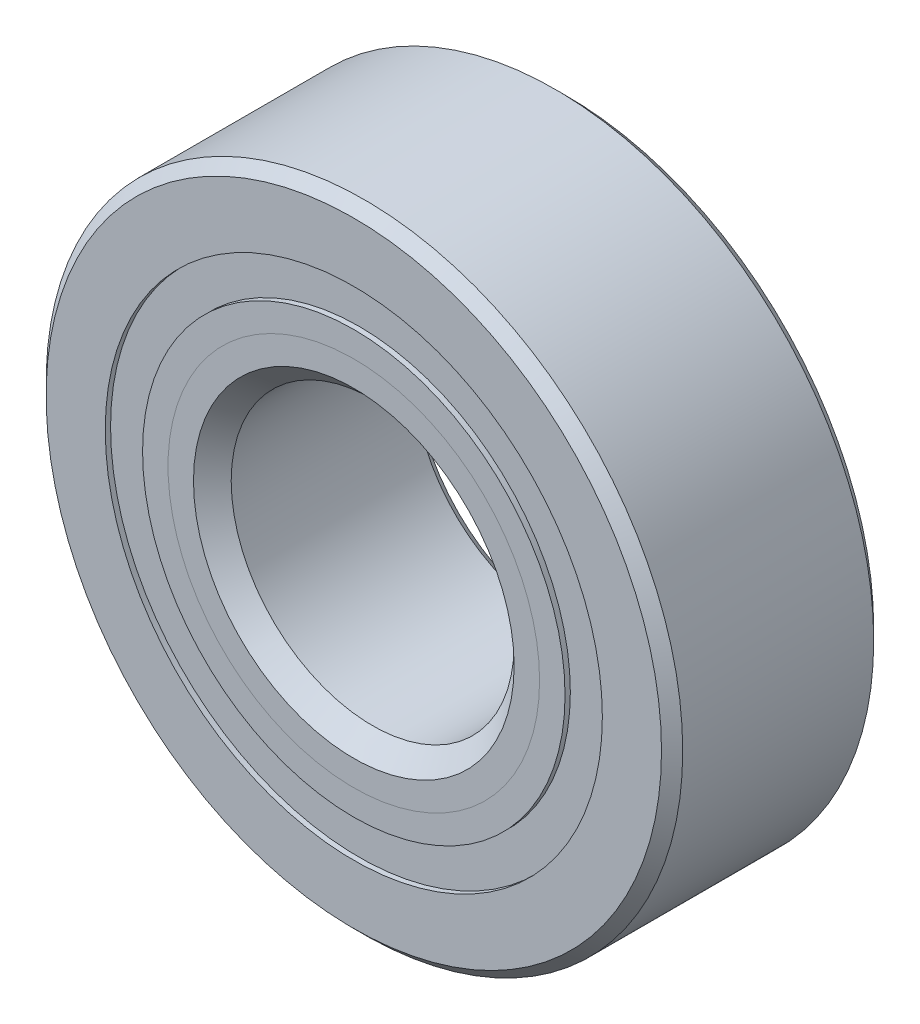
from build123d import *

# Parameters (mm, degrees)
CIRPATTERN1_COUNT = 10
SKETCH5_W         = 2.248094269
SKETCH5_H         = 1.674725274


with BuildPart() as part:
    # Sketch1 → Revolve1 (revolve)
    with BuildSketch(Plane(origin=(0, 0, 0), x_dir=(0, 0, -1), z_dir=(1, 0, 0))):
        with BuildLine():
            Line((4.28625, 14.2875), (-4.28625, 14.2875))
            Line((-4.28625, 14.2875), (-4.7625, 13.81125))
            Line((-4.7625, 13.81125), (-4.7625, 11.156112637))
            Line((-4.7625, 11.156112637), (-2.116666667, 11.156112637))
            ThreePointArc((-2.116666667, 11.156112637), (0, 12.595030731), (2.116666667, 11.156112637))
            Line((2.116666667, 11.156112637), (4.7625, 11.156112637))
            Line((4.7625, 11.156112637), (4.7625, 13.81125))
            Line((4.7625, 13.81125), (4.28625, 14.2875))
        make_face()
    revolve(axis=Axis((0, 0, 4.7625), (0, 0, -1)))


with BuildPart() as body_2:
    # Sketch2 → Revolve2 (revolve)
    with BuildSketch(Plane(origin=(0, 0, 0), x_dir=(0, 0, -1), z_dir=(1, 0, 0))):
        with BuildLine():
            Line((-4.7625, 9.481387363), (-2.116666667, 9.481387363))
            ThreePointArc((-2.116666667, 9.481387363), (-1.279722925, 8.436261434), (0, 8.042469269))
            Line((0, 8.042469269), (0, 7.196234635))
            Line((0, 7.196234635), (-3.619923636, 7.196234635))
            Line((-3.619923636, 7.196234635), (-4.7625, 8.338810999))
            Line((-4.7625, 8.338810999), (-4.7625, 9.481387363))
        make_face()
    revolve(axis=Axis((0, 0, 4.7625), (0, 0, -1)))


with BuildPart() as body_3:
    # Sketch3 → Revolve3 (revolve)
    with BuildSketch(Plane(origin=(0, 0, 0), x_dir=(0, 0, -1), z_dir=(1, 0, 0))):
        with BuildLine():
            Line((-4.7625, 8.338810999), (-3.619923636, 7.196234635))
            Line((-3.619923636, 7.196234635), (0, 7.196234635))
            Line((0, 7.196234635), (0, 8.042469269))
            ThreePointArc((0, 8.042469269), (1.279722925, 8.436261434), (2.116666667, 9.481387363))
            Line((2.116666667, 9.481387363), (4.7625, 9.481387363))
            Line((4.7625, 9.481387363), (4.7625, 6.82625))
            Line((4.7625, 6.82625), (4.28625, 6.35))
            Line((4.28625, 6.35), (-3.916265365, 6.35))
            Line((-3.916265365, 6.35), (-4.7625, 7.196234635))
            Line((-4.7625, 7.196234635), (-4.7625, 8.338810999))
        make_face()
    revolve(axis=Axis((0, 0, 4.7625), (0, 0, -1)))


with BuildPart() as body_4:
    # Sketch4 → Revolve4 (revolve)
    with BuildSketch(Plane(origin=(0, 0, 0), x_dir=(0, 0, -1), z_dir=(1, 0, 0))):
        with BuildLine():
            Line((-2.276280731, 10.31875), (2.276280731, 10.31875))
            ThreePointArc((2.276280731, 10.31875), (0, 12.595030731), (-2.276280731, 10.31875))
        make_face()
    revolve(axis=Axis((0, 10.31875, 2.276280731), (0, 0, -1)))


with BuildPart() as cirpattern1_1:
    # CirPattern1: pattern copy
    add(body_4.part.rotate(Axis((0, 0, -4.7625), (0, 0, 1)), 1 * 360 / CIRPATTERN1_COUNT))


with BuildPart() as cirpattern1_2:
    # CirPattern1: pattern copy
    add(body_4.part.rotate(Axis((0, 0, -4.7625), (0, 0, 1)), 2 * 360 / CIRPATTERN1_COUNT))


with BuildPart() as cirpattern1_3:
    # CirPattern1: pattern copy
    add(body_4.part.rotate(Axis((0, 0, -4.7625), (0, 0, 1)), 3 * 360 / CIRPATTERN1_COUNT))


with BuildPart() as cirpattern1_4:
    # CirPattern1: pattern copy
    add(body_4.part.rotate(Axis((0, 0, -4.7625), (0, 0, 1)), 4 * 360 / CIRPATTERN1_COUNT))


with BuildPart() as cirpattern1_5:
    # CirPattern1: pattern copy
    add(body_4.part.rotate(Axis((0, 0, -4.7625), (0, 0, 1)), 5 * 360 / CIRPATTERN1_COUNT))


with BuildPart() as cirpattern1_6:
    # CirPattern1: pattern copy
    add(body_4.part.rotate(Axis((0, 0, -4.7625), (0, 0, 1)), 6 * 360 / CIRPATTERN1_COUNT))


with BuildPart() as cirpattern1_7:
    # CirPattern1: pattern copy
    add(body_4.part.rotate(Axis((0, 0, -4.7625), (0, 0, 1)), 7 * 360 / CIRPATTERN1_COUNT))


with BuildPart() as cirpattern1_8:
    # CirPattern1: pattern copy
    add(body_4.part.rotate(Axis((0, 0, -4.7625), (0, 0, 1)), 8 * 360 / CIRPATTERN1_COUNT))


with BuildPart() as cirpattern1_9:
    # CirPattern1: pattern copy
    add(body_4.part.rotate(Axis((0, 0, -4.7625), (0, 0, 1)), 9 * 360 / CIRPATTERN1_COUNT))


with BuildPart() as body_14:
    # Sketch5 → Revolve5 (revolve)
    with BuildSketch(Plane(origin=(0, 0, 0), x_dir=(0, 0, -1), z_dir=(1, 0, 0))):
        with Locations((-3.400327865, 10.31875)):
            Rectangle(SKETCH5_W, SKETCH5_H)
        with Locations((3.400327865, 10.31875)):
            Rectangle(SKETCH5_W, SKETCH5_H)
    revolve(axis=Axis((0, 0, 4.7625), (0, 0, -1)))


solid = Compound([part.part, body_2.part, body_3.part, body_4.part, cirpattern1_1.part, cirpattern1_2.part, cirpattern1_3.part, cirpattern1_4.part, cirpattern1_5.part, cirpattern1_6.part, cirpattern1_7.part, cirpattern1_8.part, cirpattern1_9.part, body_14.part])
